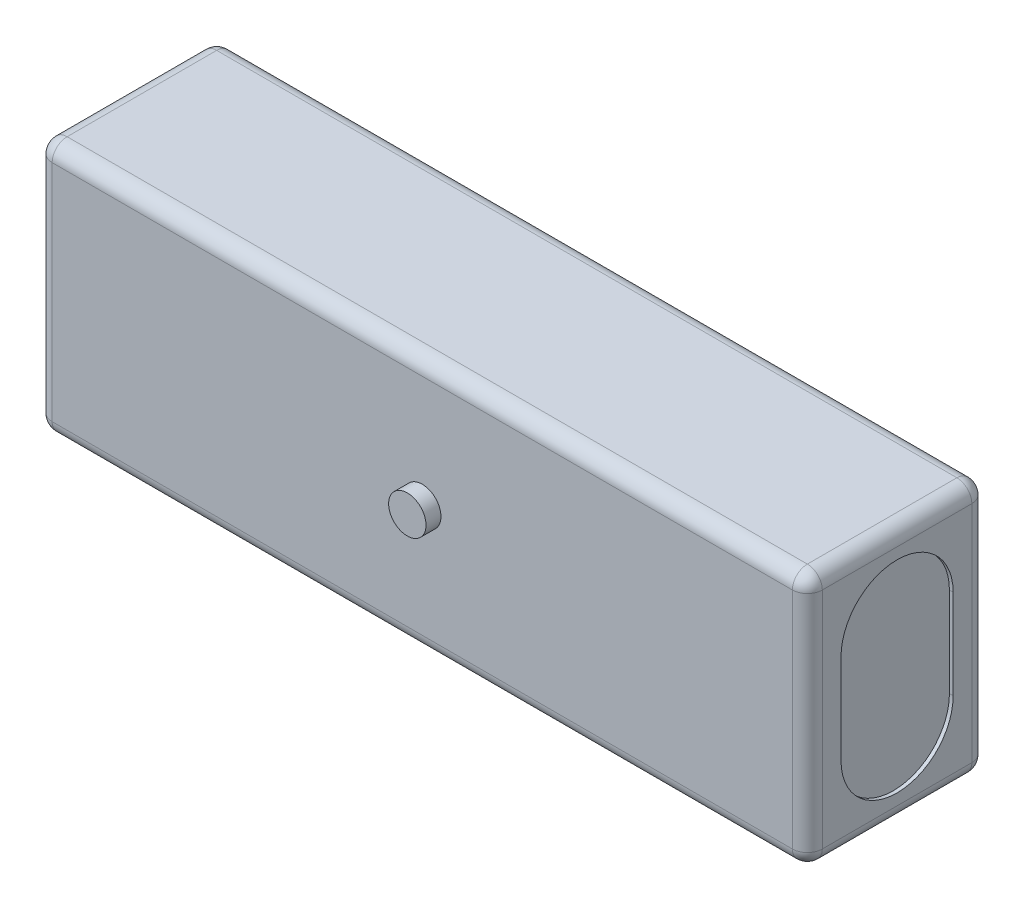
from build123d import *

# Parameters (mm, degrees)
ESBO_O1_W                = 103
ESBO_O1_H                = 34
RESSALTO_EXTRUS_O1_DEPTH = 24
CORTE_EXTRUS_O1_DEPTH    = 0.5
FILETE1_R                = 2
SKETCH1_R                = 2.5
BOSS_EXTRUDE1_DEPTH      = 2


with BuildPart() as part:
    # Esboço1 → Ressalto-extrusão1 (new body)
    with BuildSketch(Plane.XY):
        Rectangle(ESBO_O1_W, ESBO_O1_H)
    extrude(amount=RESSALTO_EXTRUS_O1_DEPTH)

    # Esboço2 → Corte-extrusão1 (cut)
    with BuildSketch(Plane(origin=(51.5, 0, 0), x_dir=(0, 0, -1), z_dir=(1, 0, 0))):
        with BuildLine():
            Line((-4.5, 6), (-4.5, -6))
            ThreePointArc((-4.5, -6), (-12, -13.5), (-19.5, -6))
            Line((-19.5, -6), (-19.5, 6))
            ThreePointArc((-19.5, 6), (-12, 13.5), (-4.5, 6))
        make_face()
    corte_extrus_o1 = extrude(amount=-CORTE_EXTRUS_O1_DEPTH, mode=Mode.SUBTRACT)

    # Espelhar1: Corte-extrusão1 across plane
    add(corte_extrus_o1.mirror(Plane(origin=(0, 0, 0), x_dir=(0, 0, 1), z_dir=(1, 0, 0))), mode=Mode.SUBTRACT)

    # Filete1
    filete1_edges = [part.edges().sort_by_distance(p)[0] for p in [
        (-51.5, 0, 24),
        (0, -17, 24),
        (51.5, 0, 24),
        (0, -17, 0),
        (-51.5, 0, 0),
        (0, 17, 0),
        (51.5, 0, 0),
        (0, 17, 24),
        (51.5, -17, 12),
        (-51.5, -17, 12),
        (-51.5, 17, 12),
        (51.5, 17, 12),
    ]]
    fillet(filete1_edges, radius=FILETE1_R)

    # Sketch1 → Boss-Extrude1 (add)
    with BuildSketch(Plane.XY.offset(24)):
        Circle(SKETCH1_R)
    extrude(amount=BOSS_EXTRUDE1_DEPTH)


solid = part.part
